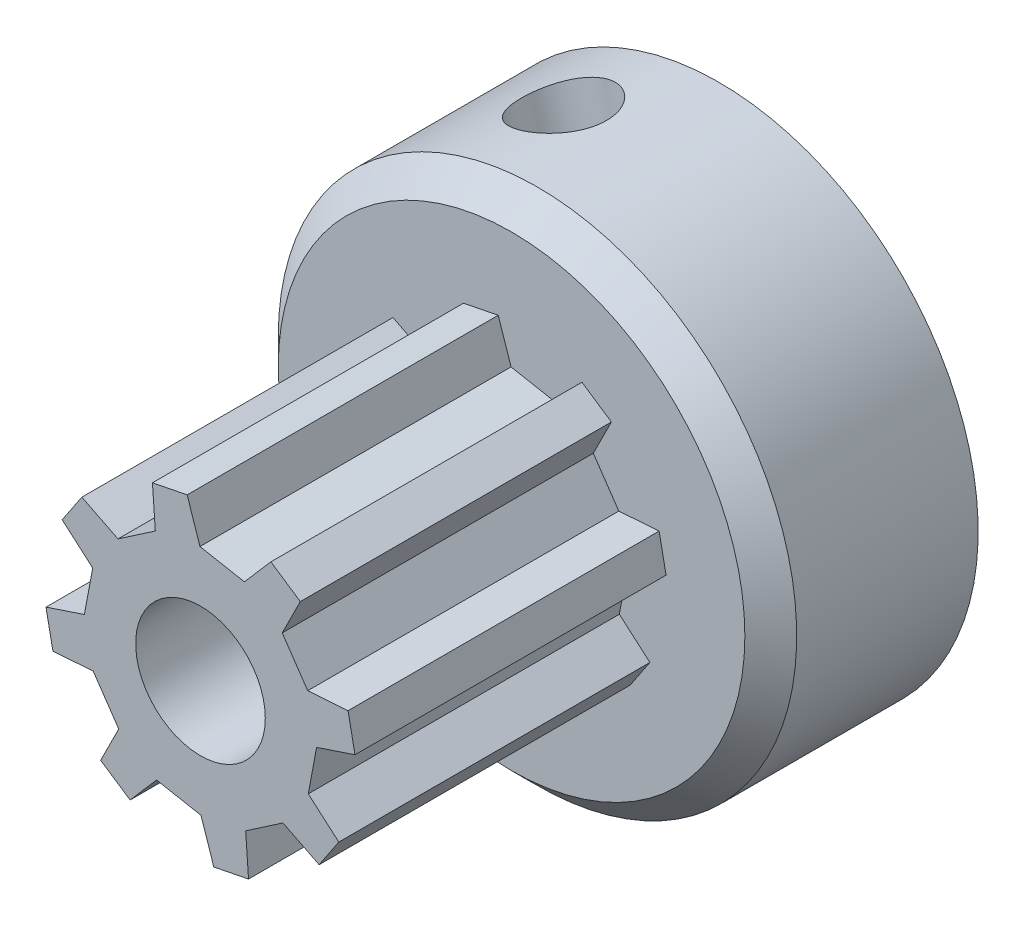
from build123d import *

# Parameters (mm, degrees)
SKETCH1_R               = 2.500000508
BOSS_EXTRUDE1_DEPTH     = 12
SKETCH2_R               = 10
BOSS_EXTRUDE2_DEPTH     = 8
CUT_EXTRUDE5_DEPTH      = 6.8
SKETCH10_R              = 2.500000508
CUT_EXTRUDE6_DEPTH      = 10
CHAMFER1_SIZE           = 1
SKETCH11_R              = 1.7
CUT_EXTRUDE7_DEPTH      = 10
CUT_EXTRUDE7_DEPTH_BACK = 2


with BuildPart() as part:
    # Sketch1 → Boss-Extrude1 (new body)
    with BuildSketch(Plane.XY.offset(15)):
        Polygon((-0.020282, 4.479718), (1.693392048, 4.157458362), (2.715058109, 5.335905553), (3.851065458, 4.576848343), (3.153297436, 3.181980515), (4.137176, 1.742358), (5.692891, 1.853219), (5.959435, 0.513206), (4.479718, 0.020282), (4.157458362, -1.693392048), (5.335905553, -2.715058109), (4.576848343, -3.851065458), (3.181980515, -3.153297436), (1.742358, -4.137176), (1.853219, -5.692891), (0.513206, -5.959435), (0.020282, -4.479718), (-1.693392048, -4.157458362), (-2.715058109, -5.335905553), (-3.851065458, -4.576848343), (-3.153297436, -3.181980515), (-4.137176, -1.742358), (-5.692891, -1.853219), (-5.959435, -0.513206), (-4.479718, -0.020282), (-4.157458362, 1.693392048), (-5.335905553, 2.715058109), (-4.576848343, 3.851065458), (-3.181980515, 3.153297436), (-1.742358, 4.137176), (-1.853219, 5.692891), (-0.513206, 5.959435), align=None)
        Circle(SKETCH1_R, mode=Mode.SUBTRACT)
    extrude(amount=-BOSS_EXTRUDE1_DEPTH)

    # Sketch2 → Boss-Extrude2 (add)
    with BuildSketch(Plane(origin=(0, 0, 3), x_dir=(-1, 0, 0), z_dir=(0, 0, -1))):
        Circle(SKETCH2_R)
    extrude(amount=BOSS_EXTRUDE2_DEPTH)

    # Sketch9 → Cut-Extrude5 (cut)
    with BuildSketch(Plane(origin=(0, 0, -5), x_dir=(-1, 0, 0), z_dir=(0, 0, -1))):
        Polygon((3.802129012, 2.564951973), (4.58587219, 5.460767338), (-1.20575854, 7.028253696), (-1.989501719, 4.13243833), align=None)
    extrude(amount=-CUT_EXTRUDE5_DEPTH, mode=Mode.SUBTRACT)

    # Sketch10 → Cut-Extrude6 (cut)
    with BuildSketch(Plane.XY.offset(3)):
        Circle(SKETCH10_R)
    extrude(amount=-CUT_EXTRUDE6_DEPTH, mode=Mode.SUBTRACT)

    # Chamfer1
    chamfer1_edges = [part.edges().sort_by_distance(p)[0] for p in [
        (10, 0, 3),
    ]]
    chamfer(chamfer1_edges, length=CHAMFER1_SIZE)

    # Sketch11 → Cut-Extrude7 (cut, two sides)
    with BuildSketch(Plane(origin=(-0.906313646, 3.348695152, 0), x_dir=(0.965271788, 0.261247726, 0), z_dir=(-0.261247726, 0.965271788, 0))) as cut_extrude7_sk:
        with Locations((0, 1.6)):
            Circle(SKETCH11_R)
    extrude(amount=CUT_EXTRUDE7_DEPTH, mode=Mode.SUBTRACT)
    extrude(cut_extrude7_sk.sketch, amount=-CUT_EXTRUDE7_DEPTH_BACK, mode=Mode.SUBTRACT)


solid = part.part
